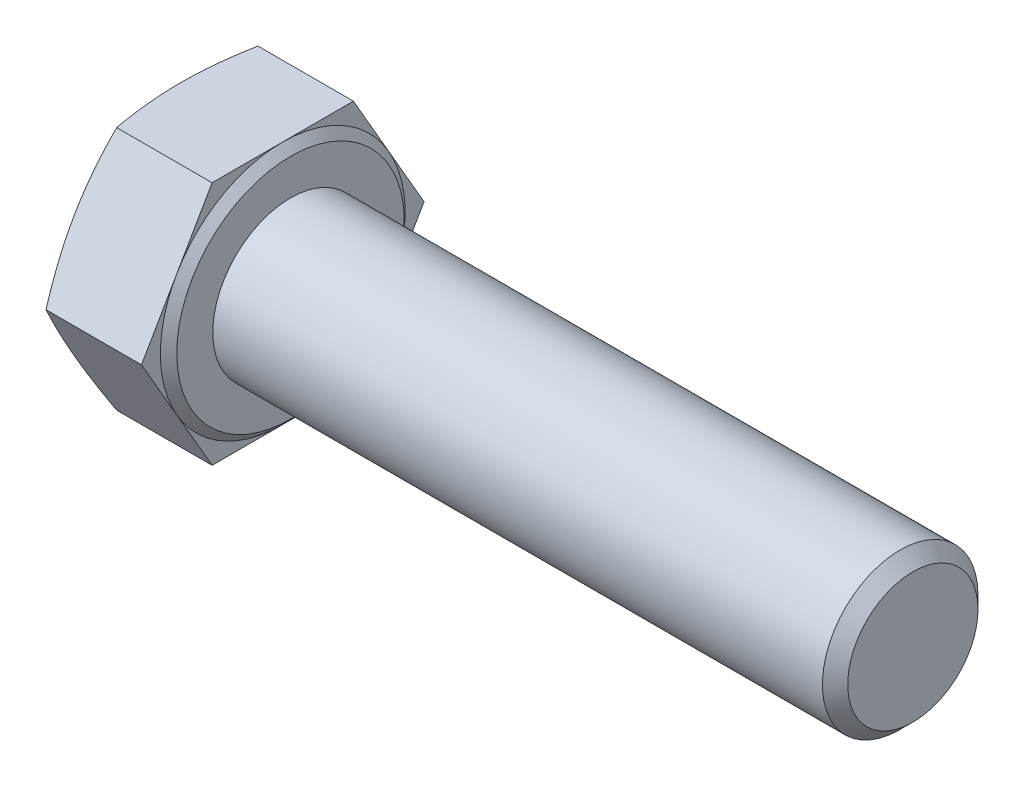
from build123d import *

# Parameters (mm, degrees)
BASEHEAD_DEPTH = 6.58
SKETCH3_R      = 5
BASEBODY_DEPTH = 40
CHAMFER1_SIZE  = 0.812


with BuildPart() as part:
    # Sketch-BaseHead → BaseHead (new body)
    with BuildSketch(Plane(origin=(0, 0, 0), x_dir=(0, 0, -1), z_dir=(1, 0, 0))):
        Polygon((9.081719734, 0), (4.540859867, 7.865), (-4.540859867, 7.865), (-9.081719734, 0), (-4.540859867, -7.865), (4.540859867, -7.865), align=None)
    extrude(amount=BASEHEAD_DEPTH)

    # Sketch4 → HeadChamfer (revolve, cut)
    with BuildSketch(Plane(origin=(-0.264637255, 0, 5.916896391), x_dir=(0, 0, -1), z_dir=(0, 1, 0))):
        Polygon((14.998616125, -0.264637255), (13.781896391, -0.264637255), (14.998616125, -0.707487022), align=None)
    revolve(axis=Axis((-4.001564945, 0, 0), (1, 0, 0)), mode=Mode.SUBTRACT)

    # Sketch1 → Revolve1 (revolve)
    with BuildSketch(Plane.XY):
        Polygon((6.58, 0), (7.08, 0), (7.08, -7.315), (6.58, -7.865), align=None)
    revolve(axis=Axis((-4.001564945, 0, 0), (1, 0, 0)))

    # Sketch3 → BaseBody (add)
    with BuildSketch(Plane(origin=(7.08, 0, 0), x_dir=(0, 0, -1), z_dir=(1, 0, 0))):
        Circle(SKETCH3_R)
    extrude(amount=BASEBODY_DEPTH)

    # Chamfer1
    chamfer1_edges = [part.edges().sort_by_distance(p)[0] for p in [
        (47.08, 0, 5),
    ]]
    chamfer(chamfer1_edges, length=CHAMFER1_SIZE)


solid = part.part
